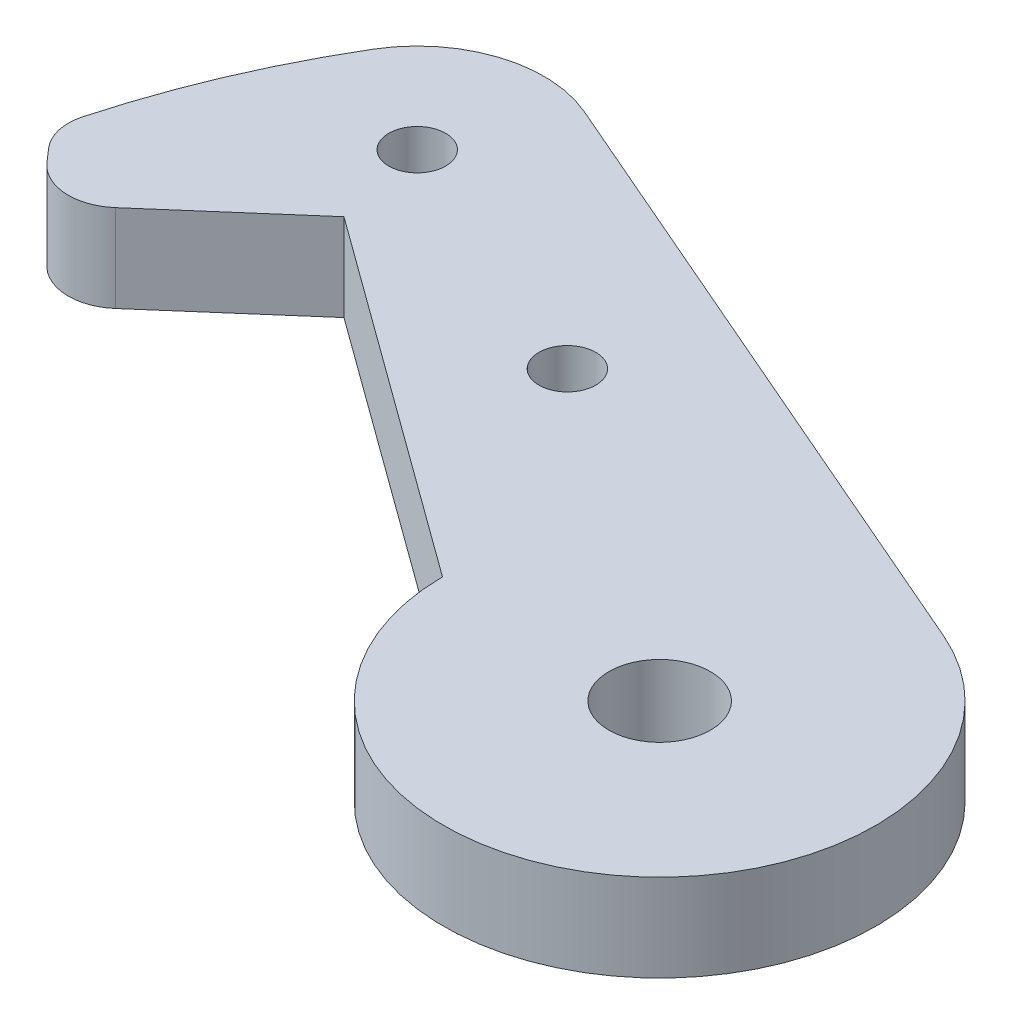
from build123d import *

# Parameters (mm, degrees)
SKETCH1_R           = 1.778
SKETCH1_R_2         = 3.175
BOSS_EXTRUDE1_DEPTH = 5.461


with BuildPart() as part:
    # Sketch1 → Boss-Extrude1 (new body)
    with BuildSketch(Plane(origin=(0, 0, 0), x_dir=(1, 0, 0), z_dir=(0, 1, 0))):
        with BuildLine():
            Line((-36.075553112, 16.34222836), (-13.499793526, -0.074664302))
            ThreePointArc((-13.499793526, -0.074664302), (7.44200849, -11.263503435), (5.363638877, 12.388760148))
            Line((5.363638877, 12.388760148), (-34.259632886, 29.543416329))
            ThreePointArc((-34.259632886, 29.543416329), (-39.855484626, 29.811728531), (-44.234733225, 26.317772344))
            ThreePointArc((-44.234733225, 26.317772344), (-47.370124011, 20.134748964), (-49.646194202, 13.586469955))
            ThreePointArc((-49.646194202, 13.586469955), (-49.677098428, 12.125807852), (-49.01441114, 10.823757773))
            Line((-49.01441114, 10.823757773), (-48.298660873, 10.002329828))
            ThreePointArc((-48.298660873, 10.002329828), (-46.071262537, 8.895051227), (-43.713289862, 9.687095487))
            Line((-43.713289862, 9.687095487), (-36.075553112, 16.34222836))
        make_face()
        with Locations((-20.862458922, 15.093717491)):
            Circle(SKETCH1_R, mode=Mode.SUBTRACT)
        Circle(SKETCH1_R_2, mode=Mode.SUBTRACT)
        with Locations((-37.413253893, 22.259284205)):
            Circle(SKETCH1_R, mode=Mode.SUBTRACT)
    extrude(amount=BOSS_EXTRUDE1_DEPTH)


solid = part.part
